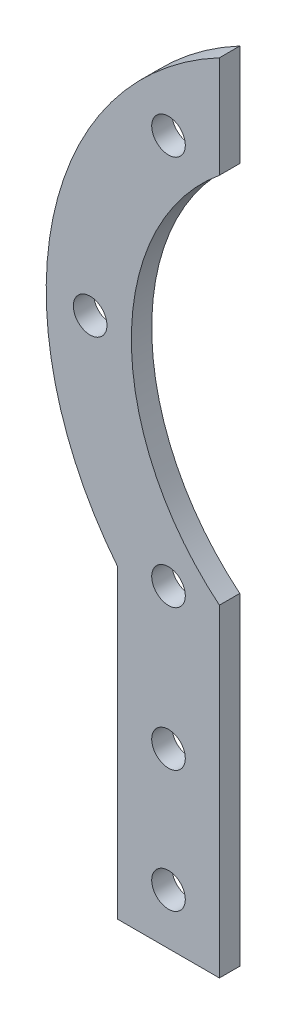
from build123d import *

# Parameters (mm, degrees)
SKETCH_1_R      = 1.65
EXTRUDE_1_DEPTH = 2


with BuildPart() as part:
    # 草图1 → 凸台-拉伸1 (new body)
    with BuildSketch(Plane.XY):
        with BuildLine():
            Line((10, 68.284271247), (10, 78.284271247))
            ThreePointArc((10, 78.284271247), (-6.350322366, 56.492864354), (0, 30))
            Line((0, 30), (0, 0))
            Line((0, 0), (10, 0))
            Line((10, 0), (10, 31.715728753))
            ThreePointArc((10, 31.715728753), (1.350167547, 50), (10, 68.284271247))
        make_face()
        with Locations((5, 5)):
            Circle(SKETCH_1_R, mode=Mode.SUBTRACT)
        with Locations((5, 17)):
            Circle(SKETCH_1_R, mode=Mode.SUBTRACT)
        with Locations((-2.697604364, 50)):
            Circle(SKETCH_1_R, mode=Mode.SUBTRACT)
        with Locations((5, 69.161348792)):
            Circle(SKETCH_1_R, mode=Mode.SUBTRACT)
        with Locations((5, 30.838651208)):
            Circle(SKETCH_1_R, mode=Mode.SUBTRACT)
    extrude(amount=EXTRUDE_1_DEPTH)


solid = part.part
